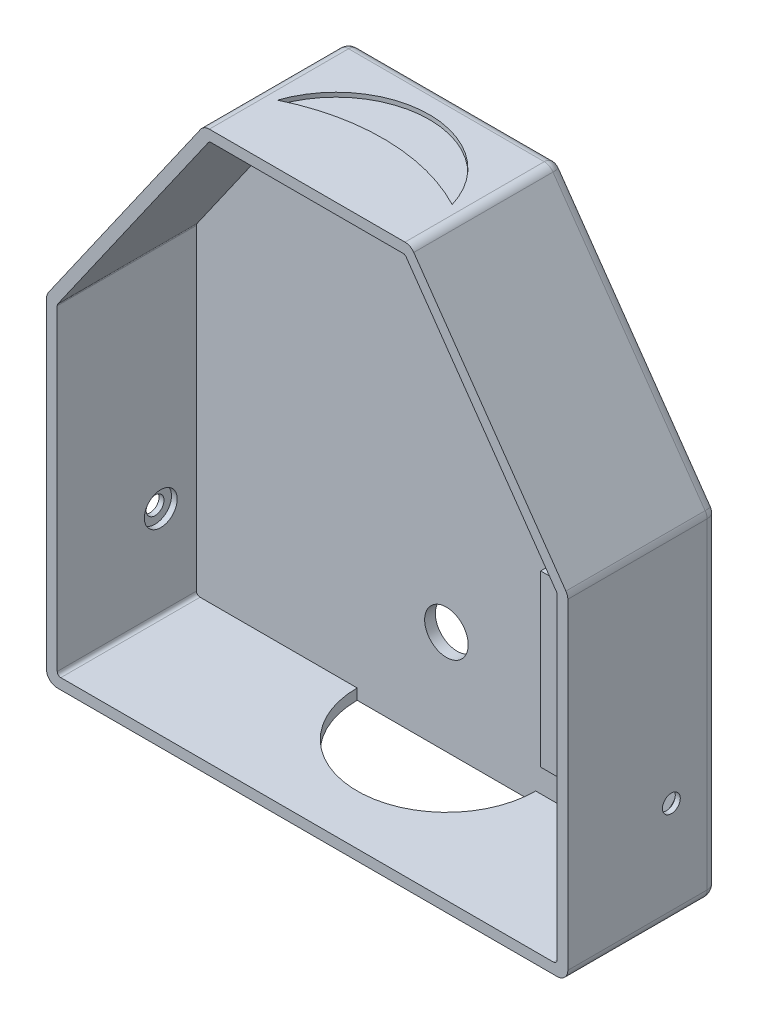
from build123d import *

# Parameters (mm, degrees)
BOSS_EXTRU_2_DEPTH       = 42
BOSS_EXTRU_3_DEPTH       = 3
CONG_5_R                 = 1
CONG_6_R                 = 3
CONG_7_R                 = 3
ESQUISSE4_R              = 4.6
ENL_V_MAT_EXTRU_1_DEPTH  = 1.6
ESQUISSE5_R              = 2.5
ENL_V_MAT_EXTRU_2_DEPTH  = 4
ESQUISSE6_R              = 4.6
ENL_V_MAT_EXTRU_3_DEPTH  = 1.6
ESQUISSE7_R              = 2.5
ENL_V_MAT_EXTRU_4_DEPTH  = 4
ENL_V_MAT_EXTRU_8_DEPTH  = 1.2
BOSS_EXTRU_4_DEPTH       = 8
ESQUISSE14_R             = 6.1
ENL_V_MAT_EXTRU_9_DEPTH  = 4
ENL_V_MAT_EXTRU_11_DEPTH = 3


with BuildPart() as part:
    # Esquisse1 → Boss.-Extru.2 (new body)
    with BuildSketch(Plane.XY):
        Polygon((-73, 90.945896367), (-28.961701152, 153.839105087), (28.961701152, 153.839105087), (73, 90.945896367), (73, -3), (-73, -3), align=None)
        Polygon((70, 0), (-70, 0), (-70, 90), (-27.4, 150.839105087), (27.4, 150.839105087), (70, 90), align=None, mode=Mode.SUBTRACT)
    extrude(amount=BOSS_EXTRU_2_DEPTH)

    # Esquisse3 → Boss.-Extru.3 (add)
    with BuildSketch(Plane.XY):
        Polygon((-70, 90), (-27.4, 150.839105087), (27.4, 150.839105087), (70, 90), (70, 0), (-70, 0), align=None)
    extrude(amount=BOSS_EXTRU_3_DEPTH)

    # Congé5
    cong_5_edges = [part.edges().sort_by_distance(p)[0] for p in [
        (70, 0, 22.5),
        (70, 90, 22.5),
        (27.4, 150.839105087, 22.5),
        (-27.4, 150.839105087, 22.5),
        (-70, 90, 22.5),
        (-70, 0, 22.5),
    ]]
    fillet(cong_5_edges, radius=CONG_5_R)

    # Congé6
    cong_6_edges = [part.edges().sort_by_distance(p)[0] for p in [
        (-73, -3, 21),
        (73, -3, 21),
        (73, 90.945896367, 21),
        (28.961701152, 153.839105087, 21),
        (-28.961701152, 153.839105087, 21),
        (-73, 90.945896367, 21),
    ]]
    fillet(cong_6_edges, radius=CONG_6_R)

    # Congé7
    cong_7_edges = [part.edges().sort_by_distance(p)[0] for p in [
        (-51.157456133, 122.140281853, 0),
        (51.157456133, 122.140281853, 0),
        (73, 45, 0),
        (0, -3, 0),
        (-28.78524584, 153.500137587, 0),
        (-72.861150852, 90.902117399, 0),
        (-72.121320344, -2.121320344, 0),
        (72.121320344, -2.121320344, 0),
        (72.861150852, 90.902117399, 0),
        (28.78524584, 153.500137587, 0),
        (0, 153.839105087, 0),
        (-73, 45, 0),
    ]]
    fillet(cong_7_edges, radius=CONG_7_R)

    # Esquisse4 → Enlèv. mat.-Extru.1 (cut)
    with BuildSketch(Plane(origin=(-70, 0, 0), x_dir=(0, 0, -1), z_dir=(1, 0, 0))):
        with Locations((-13, 26)):
            Circle(ESQUISSE4_R)
    extrude(amount=-ENL_V_MAT_EXTRU_1_DEPTH, mode=Mode.SUBTRACT)

    # Esquisse5 → Enlèv. mat.-Extru.2 (cut, through all)
    with BuildSketch(Plane(origin=(-70, 0, 0), x_dir=(0, 0, -1), z_dir=(1, 0, 0))):
        with Locations((-13, 26)):
            Circle(ESQUISSE5_R)
    extrude(amount=-ENL_V_MAT_EXTRU_2_DEPTH, mode=Mode.SUBTRACT)

    # Esquisse6 → Enlèv. mat.-Extru.3 (cut)
    with BuildSketch(Plane.ZY.offset(-70)):
        with Locations((13, 26)):
            Circle(ESQUISSE6_R)
    extrude(amount=-ENL_V_MAT_EXTRU_3_DEPTH, mode=Mode.SUBTRACT)

    # Esquisse7 → Enlèv. mat.-Extru.4 (cut, through all)
    with BuildSketch(Plane.ZY.offset(-70)):
        with Locations((13, 26)):
            Circle(ESQUISSE7_R)
    extrude(amount=-ENL_V_MAT_EXTRU_4_DEPTH, mode=Mode.SUBTRACT)

    # Esquisse12 → Enlèv. mat.-Extru.8 (cut)
    with BuildSketch(Plane(origin=(0, 153.839105087, 0), x_dir=(1, 0, 0), z_dir=(0, 1, 0))):
        with BuildLine():
            ThreePointArc((24.9, -26.291388692), (0.316807272, -7.658549634), (-24.9, -25.424491407))
            ThreePointArc((-24.9, -25.424491407), (0.10338435, -19.918896621), (24.9, -26.291388692))
        make_face()
    extrude(amount=-ENL_V_MAT_EXTRU_8_DEPTH, mode=Mode.SUBTRACT)

    # Esquisse13 → Boss.-Extru.4 (add)
    with BuildSketch(Plane.ZY.offset(-70)):
        Polygon((3, 89.684701211), (3, 88.684701211), (37.6, 88.684701211), (37.6, 43.084701211), (3, 43.084701211), (3, 42.084701211), (38.6, 42.084701211), (38.6, 89.684701211), align=None)
    extrude(amount=BOSS_EXTRU_4_DEPTH)

    # Esquisse14 → Enlèv. mat.-Extru.9 (cut, through all)
    with BuildSketch(Plane.XY.offset(3)):
        with Locations((0, 26)):
            Circle(ESQUISSE14_R)
    extrude(amount=-ENL_V_MAT_EXTRU_9_DEPTH, mode=Mode.SUBTRACT)

    # Esquisse16 → Enlèv. mat.-Extru.11 (cut)
    with BuildSketch(Plane.XZ.offset(3)):
        with BuildLine():
            Line((-25, 3), (25, 3))
            ThreePointArc((25, 3), (0, 28), (-25, 3))
        make_face()
    extrude(amount=-ENL_V_MAT_EXTRU_11_DEPTH, mode=Mode.SUBTRACT)


solid = part.part
